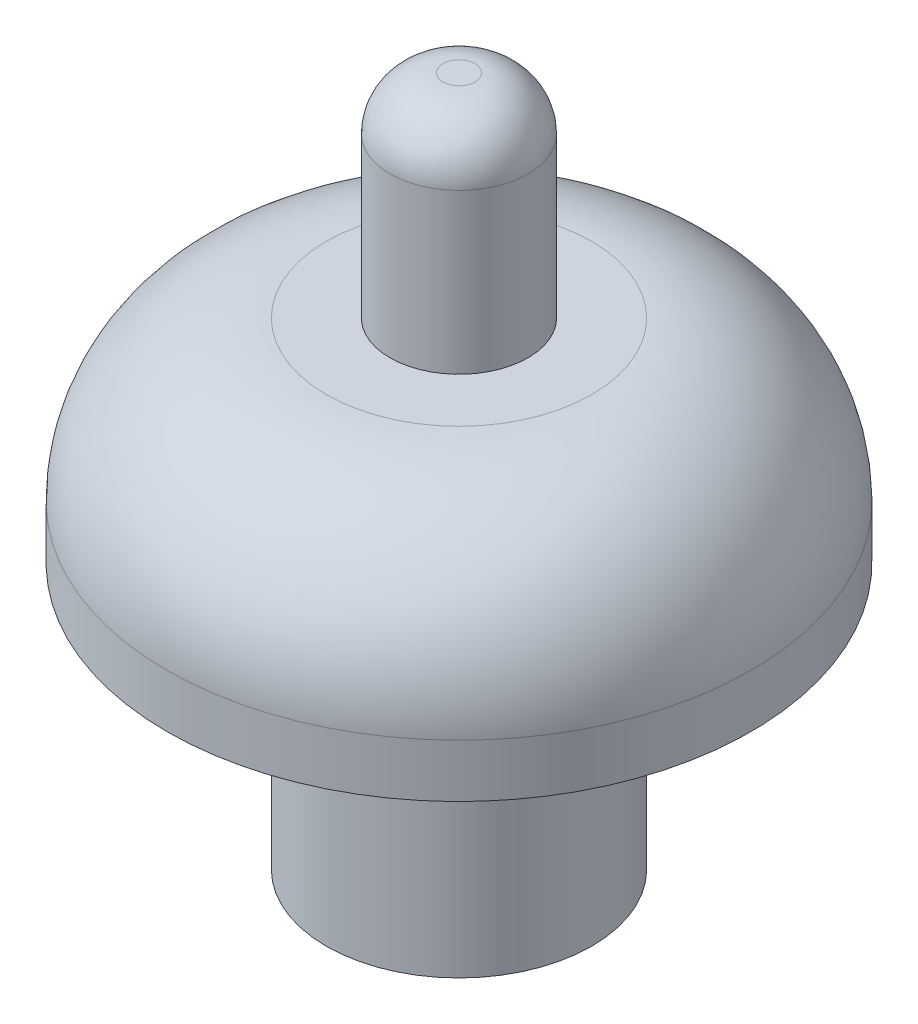
from build123d import *

# Parameters (mm, degrees)
IZIM1_R                     = 2.5
IZIM1_R_2                   = 2
Y_KSEKLIK_EKSTR_ZYON1_DEPTH = 9
IZIM2_R                     = 5.5
Y_KSEKLIK_EKSTR_ZYON2_DEPTH = 4
RADYUS1_R                   = 3
IZIM3_R                     = 1.300236586
Y_KSEKLIK_EKSTR_ZYON3_DEPTH = 4
RADYUS2_R                   = 1


with BuildPart() as part:
    # Çizim1 → Yükseklik-Ekstrüzyon1 (new body)
    with BuildSketch(Plane(origin=(0, 0, 0), x_dir=(1, 0, 0), z_dir=(0, 1, 0))):
        with Locations(Location((0, 0, 0), (0, 0, 270))):
            Circle(IZIM1_R)
        with Locations(Location((0, 0, 0), (0, 0, 270))):
            Circle(IZIM1_R_2, mode=Mode.SUBTRACT)
    extrude(amount=Y_KSEKLIK_EKSTR_ZYON1_DEPTH)



with BuildPart() as body_2:
    # Çizim2 → Yükseklik-Ekstrüzyon2 (new body)
    with BuildSketch(Plane(origin=(0, 9, 0), x_dir=(1, 0, 0), z_dir=(0, 1, 0))):
        with Locations(Location((0, 0, 0), (0, 0, 270))):
            Circle(IZIM2_R)
    extrude(amount=-Y_KSEKLIK_EKSTR_ZYON2_DEPTH)

    # Radyus1
    radyus1_edges = [body_2.edges().sort_by_distance(p)[0] for p in [
        (0, 9, -5.5),
    ]]
    fillet(radyus1_edges, radius=RADYUS1_R)


with BuildPart() as part_1:
    add(part.part)

    add(body_2.part)  # Yükseklik-Ekstrüzyon3 merges body 2
    # Çizim3 → Yükseklik-Ekstrüzyon3 (add)
    with BuildSketch(Plane(origin=(0, 9, 0), x_dir=(1, 0, 0), z_dir=(0, 1, 0))):
        with Locations(Location((0, 0, 0), (0, 0, 270))):
            Circle(IZIM3_R)
    extrude(amount=Y_KSEKLIK_EKSTR_ZYON3_DEPTH)

    # Radyus2
    radyus2_edges = [part_1.edges().sort_by_distance(p)[0] for p in [
        (0, 13, -1.300236586),
    ]]
    fillet(radyus2_edges, radius=RADYUS2_R)


solid = part_1.part
